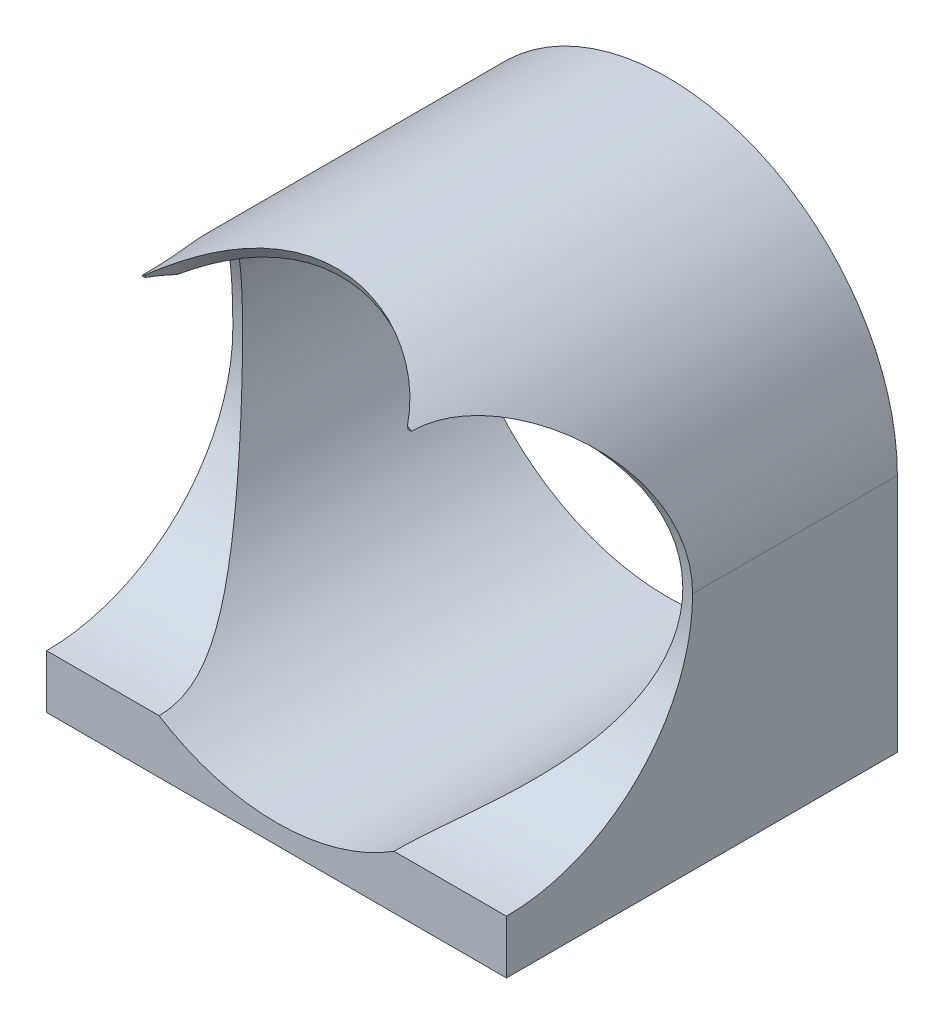
from build123d import *

# Parameters (mm, degrees)
SKETCH1_R           = 23.525
SKETCH1_R_2         = 22.525
BOSS_EXTRUDE1_DEPTH = 40
BOSS_EXTRUDE2_DEPTH = 40
SKETCH2_R           = 19.05
CUT_EXTRUDE1_DEPTH  = 59.025
SKETCH4_R           = 15.85
CUT_EXTRUDE2_DEPTH  = 22.144130073


with BuildPart() as part:
    # Sketch1 → Boss-Extrude1 (new body)
    with BuildSketch(Plane.XY):
        Circle(SKETCH1_R)
        Circle(SKETCH1_R_2, mode=Mode.SUBTRACT)
    extrude(amount=-BOSS_EXTRUDE1_DEPTH)

    # Sketch5 → Boss-Extrude2 (add)
    with BuildSketch(Plane(origin=(0, 0, -40), x_dir=(-1, 0, 0), z_dir=(0, 0, -1))):
        with BuildLine():
            ThreePointArc((0, -23.525), (-16.634687027, -16.634687027), (-23.525, 0))
            Line((-23.525, 0), (-23.525, -23.525))
            Line((-23.525, -23.525), (0, -23.525))
        make_face()
        with BuildLine():
            Line((23.525, -23.525), (23.525, 0))
            ThreePointArc((23.525, 0), (16.634687027, -16.634687027), (0, -23.525))
            Line((0, -23.525), (23.525, -23.525))
        make_face()
        Polygon((23.525, -23.525), (23.525, -24.525), (-23.525, -24.525), (-23.525, -23.525), (0, -23.525), align=None)
    extrude(amount=-BOSS_EXTRUDE2_DEPTH)

    # Sketch2 → Cut-Extrude1 (cut, through all)
    with BuildSketch(Plane(origin=(34.5, 0, 0), x_dir=(0, 0, -1), z_dir=(1, 0, 0))):
        Circle(SKETCH2_R)
    extrude(amount=-CUT_EXTRUDE1_DEPTH, mode=Mode.SUBTRACT)

    # Sketch4 → Cut-Extrude2 (cut, through all)
    with BuildSketch(Plane(origin=(0, 0, 0), x_dir=(1, 0, 0), z_dir=(0, -0.898794046, -0.438371147))):
        Circle(SKETCH4_R)
    extrude(amount=-CUT_EXTRUDE2_DEPTH, mode=Mode.SUBTRACT)


solid = part.part
